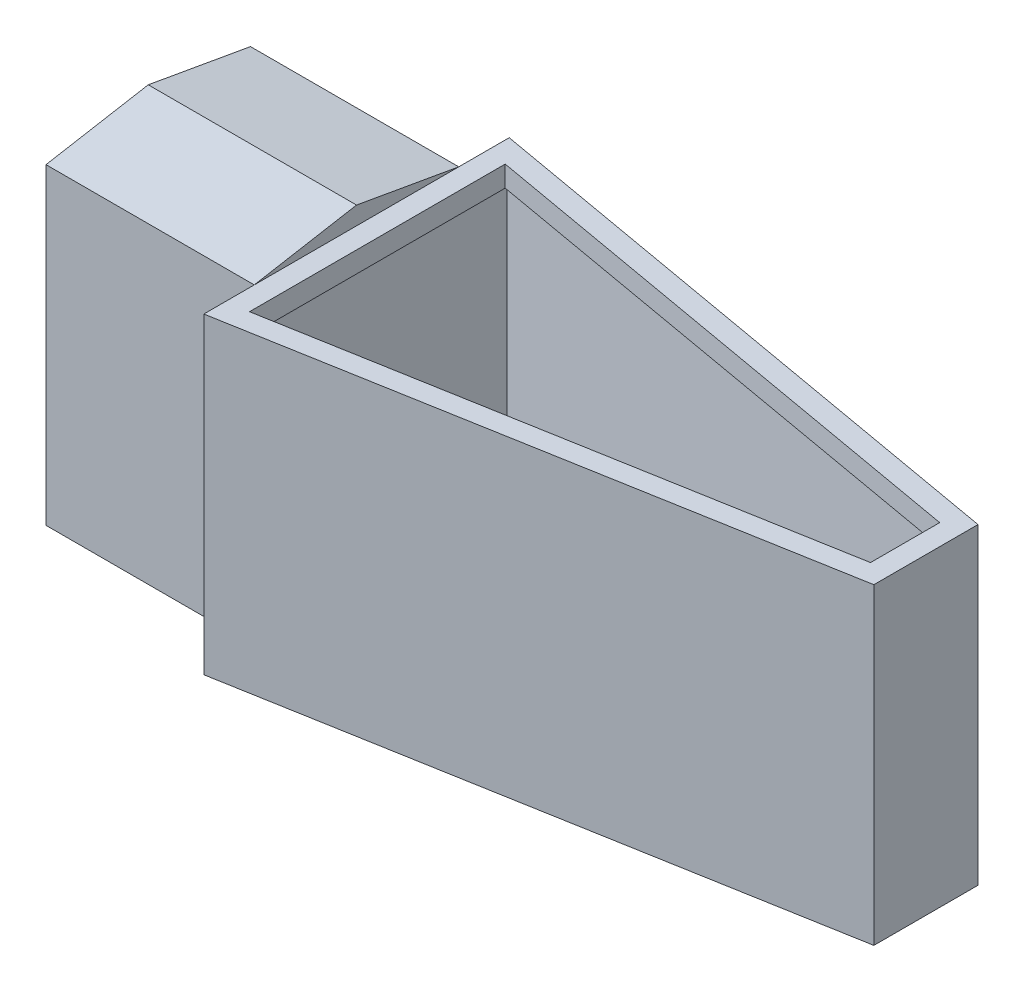
from build123d import *

# Parameters (mm, degrees)
BOSS_EXTRUDE1_DEPTH = 38.1
CUT_EXTRUDE1_DEPTH  = 2.54
CUT_EXTRUDE2_DEPTH  = 34.29
BOSS_EXTRUDE2_DEPTH = 25.4


with BuildPart() as part:
    # Sketch1 → Boss-Extrude1 (new body)
    with BuildSketch(Plane(origin=(0, 0, 0), x_dir=(1, 0, 0), z_dir=(0, 1, 0))):
        Polygon((12.853808955, 0.174987325), (12.853808955, 37.417012675), (82.296, 25.146), (82.296, 12.446), align=None)
    extrude(amount=BOSS_EXTRUDE1_DEPTH)

    # Sketch3 → Cut-Extrude1 (cut)
    with BuildSketch(Plane(origin=(0, 35.56, 0), x_dir=(1, 0, 0), z_dir=(0, 1, 0))):
        Polygon((79.756, 14.576512841), (79.756, 23.015487159), (15.393808955, 34.388821586), (15.393808955, 3.203178414), align=None)
    extrude(amount=CUT_EXTRUDE1_DEPTH, mode=Mode.SUBTRACT)

    # Sketch6 → Cut-Extrude2 (cut)
    with BuildSketch(Plane(origin=(0, 35.56, 0), x_dir=(1, 0, 0), z_dir=(0, 1, 0))):
        Polygon((81.026, 13.511256421), (81.026, 24.080743579), (14.123808955, 35.90291713), (14.123808955, 1.68908287), align=None)
    extrude(amount=-CUT_EXTRUDE2_DEPTH, mode=Mode.SUBTRACT)

    # Sketch8 → Boss-Extrude2 (add)
    with BuildSketch(Plane.ZY.offset(-12.853808955)):
        Polygon((-31.26502256, 38.1), (-31.26502256, 0), (-18.796, 2.1986251), (-6.32697744, 0), (-6.32697744, 38.1), (-18.796, 40.2986251), align=None)
    extrude(amount=BOSS_EXTRUDE2_DEPTH)


solid = part.part
